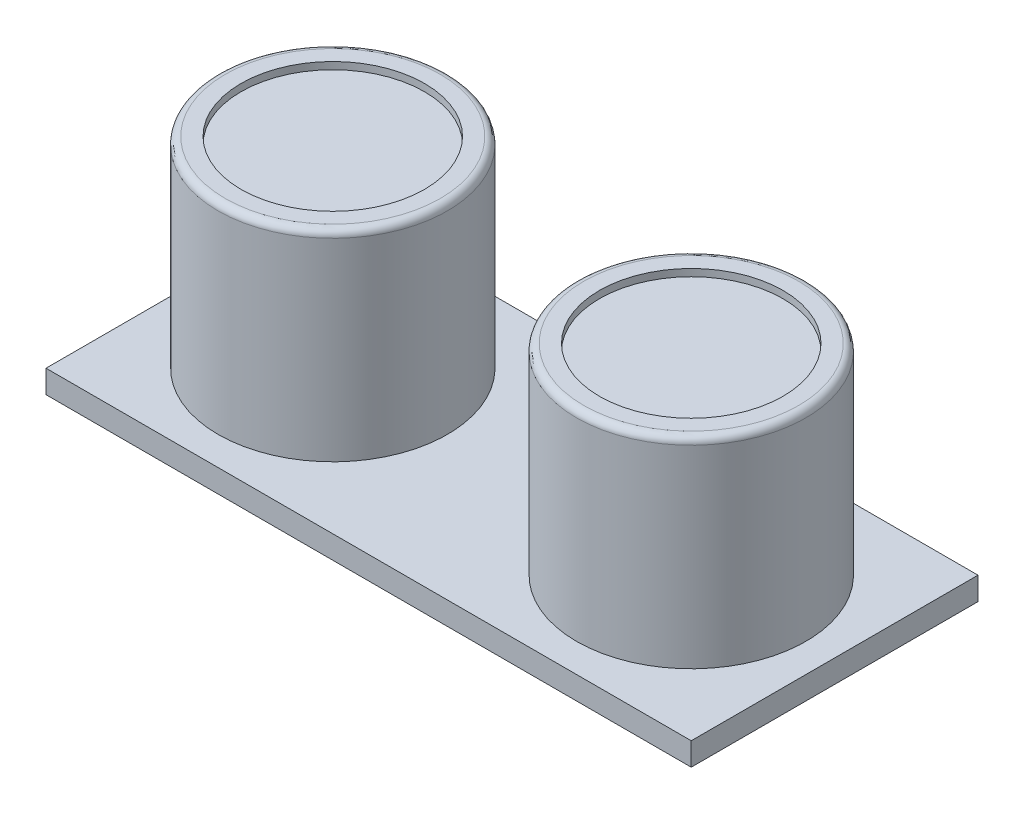
from build123d import *

# Parameters (mm, degrees)
SKETCH1_W           = 45
SKETCH1_H           = 20
BOSS_EXTRUDE1_DEPTH = 1.6
SKETCH2_R           = 8
BOSS_EXTRUDE2_DEPTH = 14
SKETCH3_R           = 6.4
CUT_EXTRUDE1_DEPTH  = 0.5
FILLET1_R           = 0.5


with BuildPart() as part:
    # Sketch1 → Boss-Extrude1 (new body)
    with BuildSketch(Plane(origin=(0, 0, 0), x_dir=(1, 0, 0), z_dir=(0, 1, 0))):
        with Locations((22.5, 10)):
            Rectangle(SKETCH1_W, SKETCH1_H)
    extrude(amount=BOSS_EXTRUDE1_DEPTH)

    # Sketch2 → Boss-Extrude2 (add)
    with BuildSketch(Plane(origin=(0, 1.6, 0), x_dir=(1, 0, 0), z_dir=(0, 1, 0))):
        with Locations((10, 10)):
            Circle(SKETCH2_R)
        with Locations((35, 10)):
            Circle(SKETCH2_R)
    extrude(amount=BOSS_EXTRUDE2_DEPTH)

    # Sketch3 → Cut-Extrude1 (cut)
    with BuildSketch(Plane(origin=(0, 15.6, 0), x_dir=(1, 0, 0), z_dir=(0, 1, 0))):
        with Locations((10, 10)):
            Circle(SKETCH3_R)
        with Locations((35, 10)):
            Circle(SKETCH3_R)
    extrude(amount=-CUT_EXTRUDE1_DEPTH, mode=Mode.SUBTRACT)

    # Fillet1
    fillet1_edges = [part.edges().sort_by_distance(p)[0] for p in [
        (2, 15.6, -10),
        (27, 15.6, -10),
    ]]
    fillet(fillet1_edges, radius=FILLET1_R)


solid = part.part
